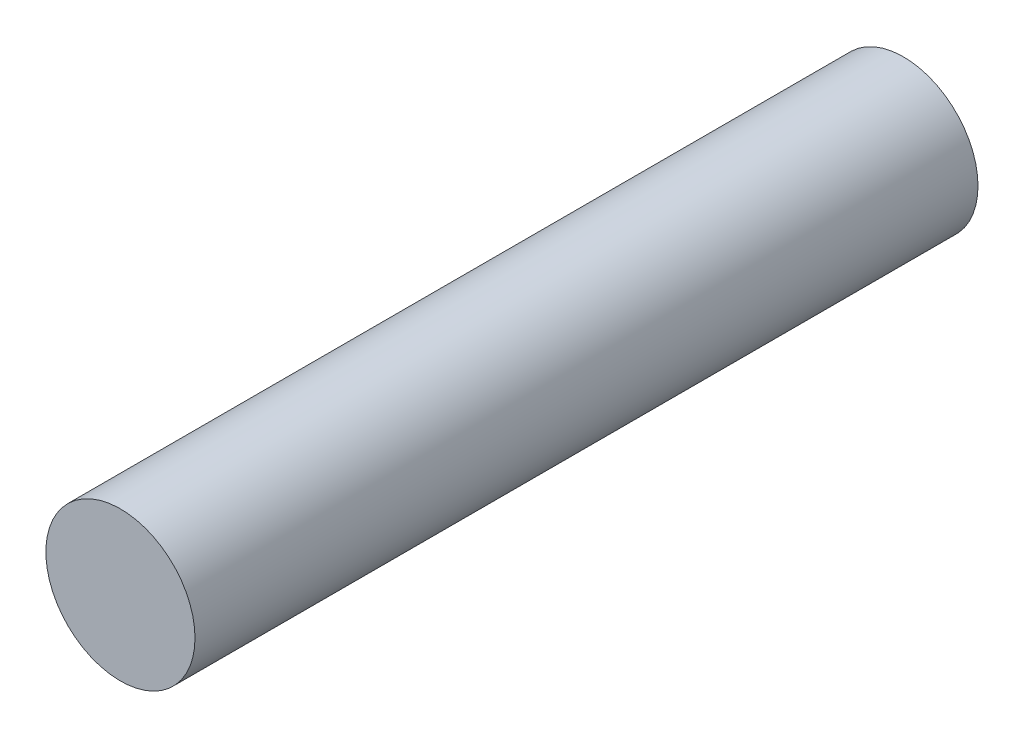
from build123d import *

# Parameters (mm, degrees)
SKETCH1_R           = 2
BOSS_EXTRUDE1_DEPTH = 21


with BuildPart() as part:
    # Sketch1 → Boss-Extrude1 (new body)
    with BuildSketch(Plane.XY):
        Circle(SKETCH1_R)
    extrude(amount=BOSS_EXTRUDE1_DEPTH)


solid = part.part
